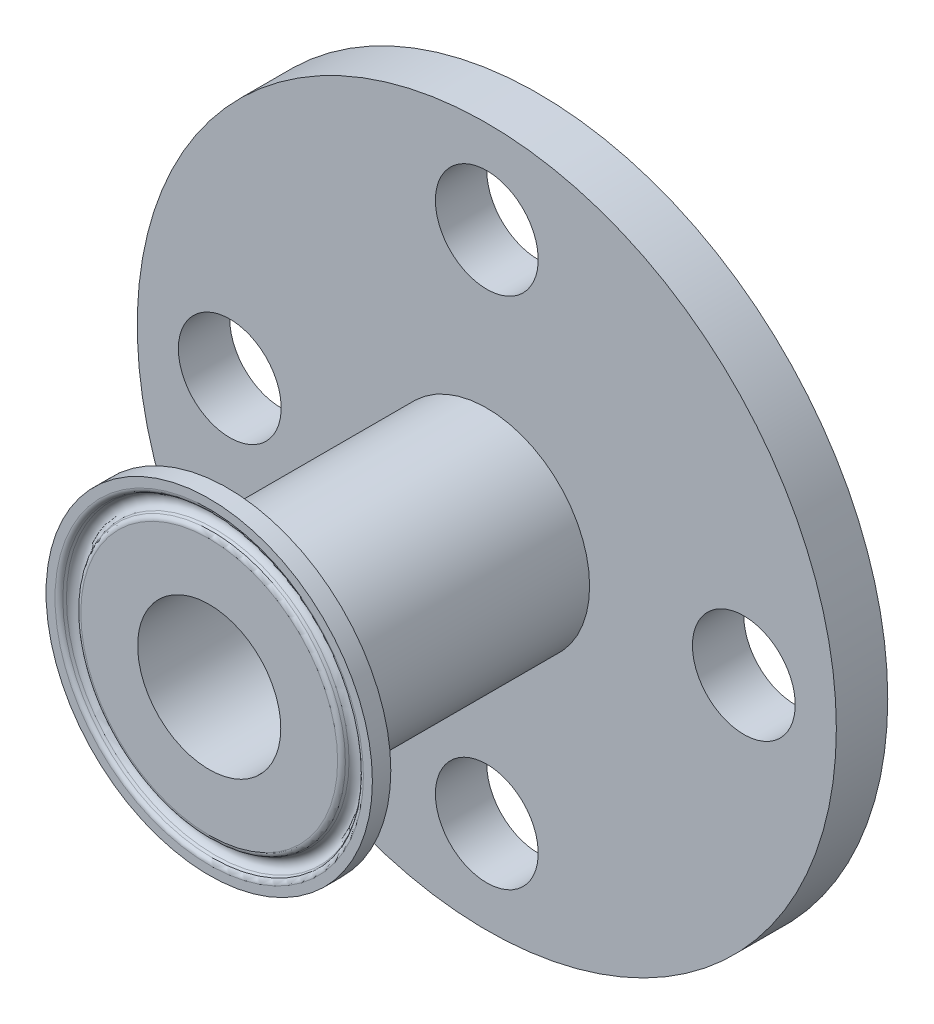
from build123d import *

# Parameters (mm, degrees)
SKETCH2_R          = 7.9375
CUT_EXTRUDE1_DEPTH = 7.9375


with BuildPart() as part:
    # Sketch1 → Revolve1 (revolve)
    with BuildSketch(Plane(origin=(0, 0, 0), x_dir=(0, 0, -1), z_dir=(1, 0, 0))):
        with BuildLine():
            Line((0, 11.049), (0, 19.828027725))
            ThreePointArc((0, 19.828027725), (0.130798304, 20.262622907), (0.479738309, 20.552833247))
            Line((0.479738309, 20.552833247), (0.872854821, 20.719701306))
            ThreePointArc((0.872854821, 20.719701306), (1.6002, 21.8186), (0.872854821, 22.917498694))
            Line((0.872854821, 22.917498694), (0.479738309, 23.084366753))
            ThreePointArc((0.479738309, 23.084366753), (0.130798304, 23.374577093), (0, 23.809172275))
            Line((0, 23.809172275), (0, 25.1968))
            Line((0, 25.1968), (2.8448, 25.1968))
            Line((2.8448, 25.1968), (5.477292593, 17.964086045))
            ThreePointArc((5.477292593, 17.964086045), (6.639711478, 16.449192259), (8.460816664, 15.875))
            Line((8.460816664, 15.875), (42.8625, 15.875))
            Line((42.8625, 15.875), (42.8625, 53.975))
            Line((42.8625, 53.975), (50.8, 53.975))
            Line((50.8, 53.975), (50.8, 28.575))
            Line((50.8, 28.575), (50.8, 11.049))
            Line((50.8, 11.049), (0, 11.049))
        make_face()
    revolve(axis=Axis((0, 0, 0), (0, 0, -1)))

    # Sketch2 → Cut-Extrude1 (cut)
    with BuildSketch(Plane(origin=(0, 0, -50.8), x_dir=(-1, 0, 0), z_dir=(0, 0, -1))):
        with Locations((0, 39.6875)):
            Circle(SKETCH2_R)
        with Locations((39.6875, 0)):
            Circle(SKETCH2_R)
        with Locations((0, -39.6875)):
            Circle(SKETCH2_R)
        with Locations((-39.6875, 0)):
            Circle(SKETCH2_R)
    extrude(amount=-CUT_EXTRUDE1_DEPTH, mode=Mode.SUBTRACT)


solid = part.part
